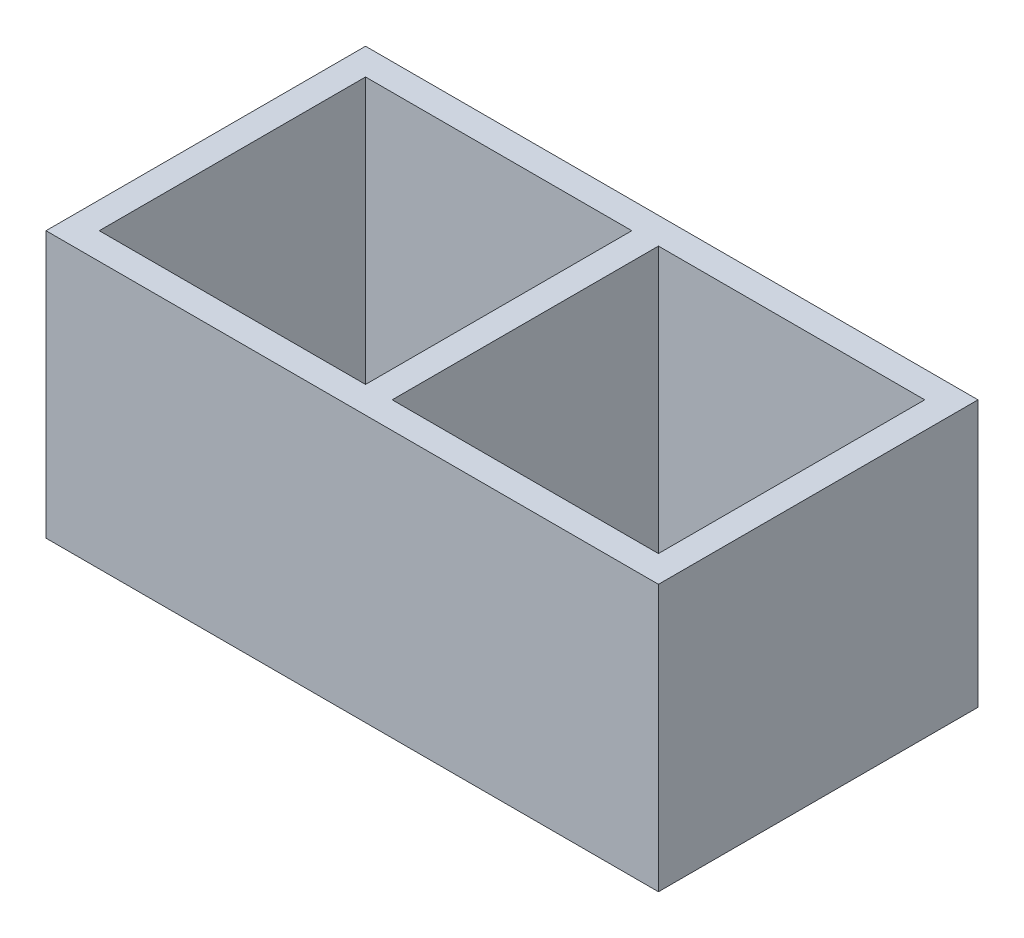
from build123d import *

# Parameters (mm, degrees)
SKETCH1_W           = 34.5
SKETCH1_H           = 18
SKETCH1_W_2         = 15
SKETCH1_H_2         = 15
BOSS_EXTRUDE1_DEPTH = 15


with BuildPart() as part:
    # Sketch1 → Boss-Extrude1 (new body)
    with BuildSketch(Plane(origin=(0, 0, 0), x_dir=(1, 0, 0), z_dir=(0, 1, 0))):
        Rectangle(SKETCH1_W, SKETCH1_H)
        with Locations((-8.25, 0)):
            Rectangle(SKETCH1_W_2, SKETCH1_H_2, mode=Mode.SUBTRACT)
        with Locations((8.25, 0)):
            Rectangle(SKETCH1_W_2, SKETCH1_H_2, mode=Mode.SUBTRACT)
    extrude(amount=BOSS_EXTRUDE1_DEPTH)


solid = part.part
